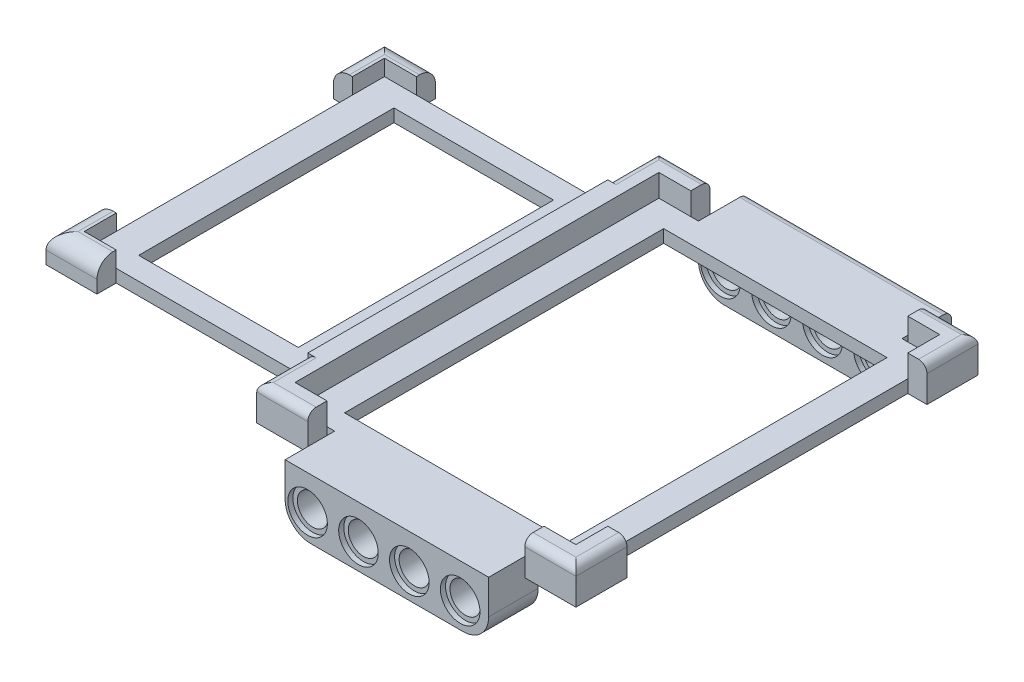
from build123d import *

# Parameters (mm, degrees)
SKETCH1_W                 = 44
SKETCH1_H                 = 57
BOSS_EXTRUDE1_DEPTH       = 2
BOSS_EXTRUDE2_DEPTH       = 3.5
BOSS_EXTRUDE2_DEPTH_BACK  = 2
SKETCH17_W                = 47.024890074
SKETCH17_H                = 2
BOSS_EXTRUDE7_DEPTH       = 38
SKETCH8_W                 = 31.89
SKETCH8_H                 = 7.76
BOSS_EXTRUDE5_DEPTH       = 9.38
SKETCH9_R                 = 2.4
CUT_EXTRUDE1_DEPTH        = 9.38
SKETCH10_R                = 3.1
CUT_EXTRUDE2_DEPTH        = 0.8
SKETCH11_R                = 3.1
CUT_EXTRUDE3_DEPTH        = 0.8
SKETCH14_R                = 2.4
CUT_EXTRUDE5_DEPTH        = 77.6
SKETCH15_R                = 3.1
CUT_EXTRUDE6_DEPTH        = 0.8
SKETCH16_R                = 3.1
CUT_EXTRUDE7_DEPTH        = 0.8
FILLET1_R                 = 1.3
FILLET2_R                 = 1.3
FILLET3_R                 = 1.3
FILLET4_R                 = 1.3
FILLET5_R                 = 1.3
FILLET7_R                 = 4
FILLET8_R                 = 4
FILLET9_R                 = 4
FILLET10_R                = 4
SKETCH19_W                = 3
SKETCH19_H                = 47
BOSS_EXTRUDE9_DEPTH       = 3.5
SKETCH20_W                = 25
SKETCH20_H                = 40
CUT_EXTRUDE8_DEPTH        = 10.38
SKETCH21_W                = 35
SKETCH21_H                = 50
CUT_EXTRUDE9_DEPTH        = 3.5
BOSS_EXTRUDE10_DEPTH      = 2.5
BOSS_EXTRUDE10_DEPTH_BACK = 2
FILLET11_R                = 2.5
FILLET12_R                = 2.5


with BuildPart() as part:
    # Sketch1 → Boss-Extrude1 (new body)
    with BuildSketch(Plane(origin=(0, 0, 0), x_dir=(1, 0, 0), z_dir=(0, 1, 0))):
        with Locations((22, 28.5)):
            Rectangle(SKETCH1_W, SKETCH1_H)
    extrude(amount=BOSS_EXTRUDE1_DEPTH)

    # Sketch2 → Boss-Extrude2 (add, two sides)
    with BuildSketch(Plane(origin=(0, 2, 0), x_dir=(1, 0, 0), z_dir=(0, 1, 0))) as boss_extrude2_sk:
        Polygon((0, 0), (0, 5), (-3, 5), (-3, 0), (-3, -3), (5, -3), (5, 0), align=None)
        Polygon((47, 0), (47, -3), (39, -3), (39, 0), (44, 0), (44, 5), (47, 5), align=None)
        Polygon((47, 57), (47, 52), (44, 52), (44, 57), (39, 57), (39, 60), (47, 60), align=None)
        Polygon((-3, 57), (-3, 60), (5, 60), (5, 57), (0, 57), (0, 52), (-3, 52), align=None)
    extrude(amount=BOSS_EXTRUDE2_DEPTH)
    extrude(boss_extrude2_sk.sketch, amount=-BOSS_EXTRUDE2_DEPTH_BACK)

    # Sketch17 → Boss-Extrude7 (add)
    with BuildSketch(Plane.ZY):
        with Locations((-28.487554963, 1)):
            Rectangle(SKETCH17_W, SKETCH17_H)
    extrude(amount=BOSS_EXTRUDE7_DEPTH)

    # Sketch8 → Boss-Extrude5 (add)
    with BuildSketch(Plane(origin=(0, 2, 0), x_dir=(1, 0, 0), z_dir=(0, 1, 0))):
        with Locations((22.150732417, 60.88)):
            Rectangle(SKETCH8_W, SKETCH8_H)
        with Locations((22.150732417, -3.88)):
            Rectangle(SKETCH8_W, SKETCH8_H)
    extrude(amount=-BOSS_EXTRUDE5_DEPTH)

    # Sketch9 → Cut-Extrude1 (cut)
    with BuildSketch(Plane(origin=(0, 0, -64.76), x_dir=(-1, 0, 0), z_dir=(0, 0, -1))):
        with Locations((-33.633843379, -3.383703118)):
            Circle(SKETCH9_R)
        with Locations((-25.663843379, -3.383703118)):
            Circle(SKETCH9_R)
        with Locations((-17.693843379, -3.383703118)):
            Circle(SKETCH9_R)
        with Locations((-9.723843379, -3.383703118)):
            Circle(SKETCH9_R)
    extrude(amount=-CUT_EXTRUDE1_DEPTH, mode=Mode.SUBTRACT)

    # Sketch10 → Cut-Extrude2 (cut)
    with BuildSketch(Plane(origin=(0, 0, -64.76), x_dir=(-1, 0, 0), z_dir=(0, 0, -1))):
        with Locations((-33.633843379, -3.383703118)):
            Circle(SKETCH10_R)
        with Locations((-25.663843379, -3.383703118)):
            Circle(SKETCH10_R)
        with Locations((-17.693843379, -3.383703118)):
            Circle(SKETCH10_R)
        with Locations((-9.723843379, -3.383703118)):
            Circle(SKETCH10_R)
    extrude(amount=-CUT_EXTRUDE2_DEPTH, mode=Mode.SUBTRACT)

    # Sketch11 → Cut-Extrude3 (cut)
    with BuildSketch(Plane.XY.offset(-57)):
        with Locations((33.633843379, -3.383703118)):
            Circle(SKETCH11_R)
        with Locations((25.633843379, -3.383703118)):
            Circle(SKETCH11_R)
        with Locations((17.633843379, -3.383703118)):
            Circle(SKETCH11_R)
        with Locations((9.633843379, -3.383703118)):
            Circle(SKETCH11_R)
    extrude(amount=-CUT_EXTRUDE3_DEPTH, mode=Mode.SUBTRACT)

    # Sketch14 → Cut-Extrude5 (cut)
    with BuildSketch(Plane.XY.offset(7.76)):
        with Locations((9.723843379, -3.383703118)):
            Circle(SKETCH14_R)
        with Locations((17.693843379, -3.383703118)):
            Circle(SKETCH14_R)
        with Locations((25.663843379, -3.383703118)):
            Circle(SKETCH14_R)
        with Locations((33.633843379, -3.383703118)):
            Circle(SKETCH14_R)
    extrude(amount=-CUT_EXTRUDE5_DEPTH, mode=Mode.SUBTRACT)

    # Sketch15 → Cut-Extrude6 (cut)
    with BuildSketch(Plane.XY.offset(7.76)):
        with Locations((9.723843379, -3.383703118)):
            Circle(SKETCH15_R)
        with Locations((17.693843379, -3.383703118)):
            Circle(SKETCH15_R)
        with Locations((25.663843379, -3.383703118)):
            Circle(SKETCH15_R)
        with Locations((33.633843379, -3.383703118)):
            Circle(SKETCH15_R)
    extrude(amount=-CUT_EXTRUDE6_DEPTH, mode=Mode.SUBTRACT)

    # Sketch16 → Cut-Extrude7 (cut)
    with BuildSketch(Plane(origin=(0, 0, 0), x_dir=(-1, 0, 0), z_dir=(0, 0, -1))):
        with Locations((-9.723843379, -3.383703118)):
            Circle(SKETCH16_R)
        with Locations((-17.693843379, -3.383703118)):
            Circle(SKETCH16_R)
        with Locations((-25.663843379, -3.383703118)):
            Circle(SKETCH16_R)
        with Locations((-33.633843379, -3.383703118)):
            Circle(SKETCH16_R)
    extrude(amount=-CUT_EXTRUDE7_DEPTH, mode=Mode.SUBTRACT)

    # Fillet1
    fillet1_edges = [part.edges().sort_by_distance(p)[0] for p in [
        (47, 5.5, -56),
        (43, 5.5, -60),
    ]]
    fillet(fillet1_edges, radius=FILLET1_R)

    # Fillet2
    fillet2_edges = [part.edges().sort_by_distance(p)[0] for p in [
        (47, 5.5, -1),
        (43, 5.5, 3),
    ]]
    fillet(fillet2_edges, radius=FILLET2_R)

    # Fillet3
    fillet3_edges = [part.edges().sort_by_distance(p)[0] for p in [
        (-3, 5.5, -56),
        (1, 5.5, -60),
    ]]
    fillet(fillet3_edges, radius=FILLET3_R)

    # Fillet4
    fillet4_edges = [part.edges().sort_by_distance(p)[0] for p in [
        (-3, 5.5, -1),
        (1, 5.5, 3),
    ]]
    fillet(fillet4_edges, radius=FILLET4_R)

    # Fillet5
    fillet5_edges = [part.edges().sort_by_distance(p)[0] for p in [
        (22.150732417, 2, -64.76),
    ]]
    fillet(fillet5_edges, radius=FILLET5_R)

    # Fillet7
    fillet7_edges = [part.edges().sort_by_distance(p)[0] for p in [
        (6.205732417, -7.38, -60.88),
    ]]
    fillet(fillet7_edges, radius=FILLET7_R)

    # Fillet8
    fillet8_edges = [part.edges().sort_by_distance(p)[0] for p in [
        (38.095732417, -7.38, -60.88),
    ]]
    fillet(fillet8_edges, radius=FILLET8_R)

    # Fillet9
    fillet9_edges = [part.edges().sort_by_distance(p)[0] for p in [
        (38.095732417, -7.38, 3.88),
    ]]
    fillet(fillet9_edges, radius=FILLET9_R)

    # Fillet10
    fillet10_edges = [part.edges().sort_by_distance(p)[0] for p in [
        (6.205732417, -7.38, 3.88),
    ]]
    fillet(fillet10_edges, radius=FILLET10_R)

    # Sketch19 → Boss-Extrude9 (add)
    with BuildSketch(Plane(origin=(0, 2, 0), x_dir=(1, 0, 0), z_dir=(0, 1, 0))):
        with Locations((-1.5, 28.5)):
            Rectangle(SKETCH19_W, SKETCH19_H)
    extrude(amount=BOSS_EXTRUDE9_DEPTH)

    # Sketch20 → Cut-Extrude8 (cut, through all)
    with BuildSketch(Plane(origin=(0, 2, 0), x_dir=(1, 0, 0), z_dir=(0, 1, 0))):
        with Locations((-20.5, 28.5)):
            Rectangle(SKETCH20_W, SKETCH20_H)
    extrude(amount=-CUT_EXTRUDE8_DEPTH, mode=Mode.SUBTRACT)

    # Sketch21 → Cut-Extrude9 (cut)
    with BuildSketch(Plane(origin=(0, 2, 0), x_dir=(1, 0, 0), z_dir=(0, 1, 0))):
        with Locations((22, 28.25)):
            Rectangle(SKETCH21_W, SKETCH21_H)
    extrude(amount=-CUT_EXTRUDE9_DEPTH, mode=Mode.SUBTRACT)

    # Sketch22 → Boss-Extrude10 (add, two sides)
    with BuildSketch(Plane(origin=(0, 2, 0), x_dir=(1, 0, 0), z_dir=(0, 1, 0))) as boss_extrude10_sk:
        Polygon((-38, 52), (-32.9998846, 52), (-32.9998846, 55.005068645), (-38, 55.005068645), (-40.988316888, 55.005068645), (-40.988316888, 46.981993776), (-38, 46.981993776), align=None)
        Polygon((-32.9998846, 4.975109926), (-32.9998846, 1.970041281), (-38, 1.970041281), (-40.988316888, 1.970041281), (-40.988316888, 9.99311615), (-38, 9.99311615), (-38, 4.975109926), align=None)
    extrude(amount=BOSS_EXTRUDE10_DEPTH)
    extrude(boss_extrude10_sk.sketch, amount=-BOSS_EXTRUDE10_DEPTH_BACK)

    # Fillet11
    fillet11_edges = [part.edges().sort_by_distance(p)[0] for p in [
        (-36.994100744, 4.5, -55.005068645),
        (-40.988316888, 4.5, -50.99353121),
    ]]
    fillet(fillet11_edges, radius=FILLET11_R)

    # Fillet12
    fillet12_edges = [part.edges().sort_by_distance(p)[0] for p in [
        (-40.988316888, 4.5, -5.981578716),
        (-36.994100744, 4.5, -1.970041281),
    ]]
    fillet(fillet12_edges, radius=FILLET12_R)


solid = part.part
